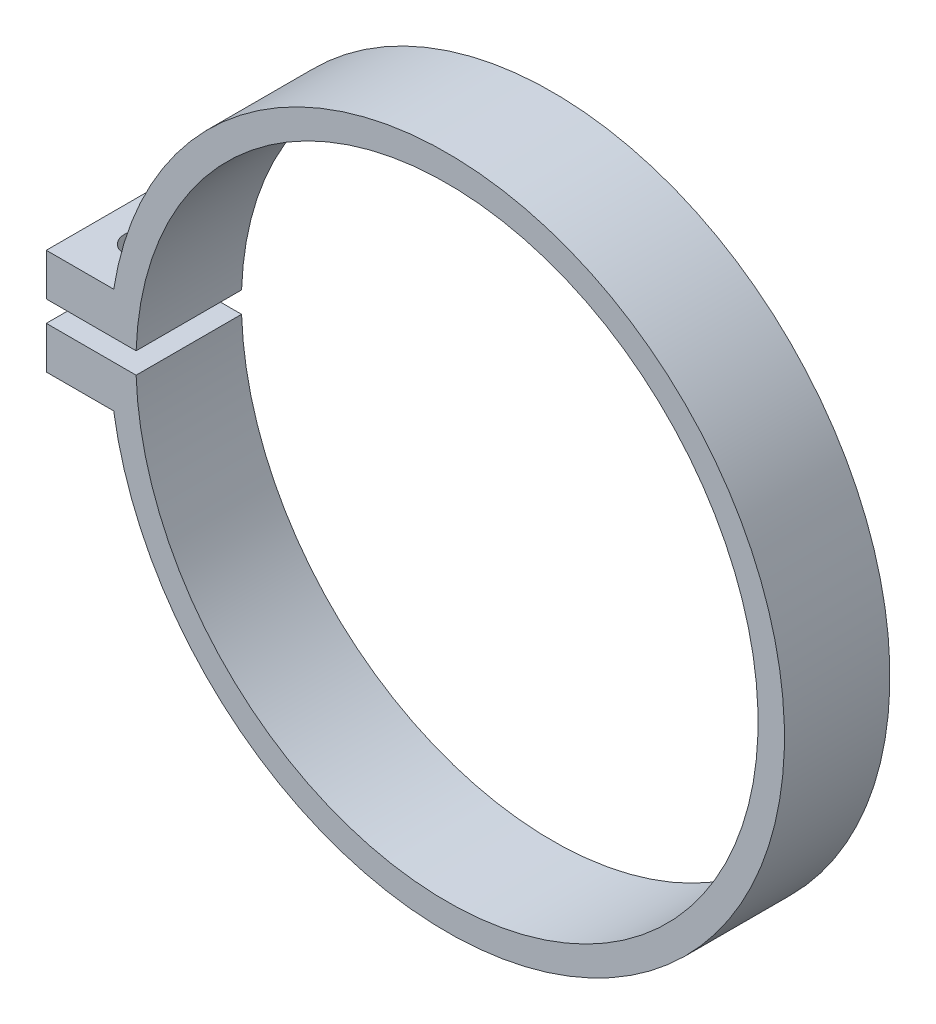
from build123d import *

# Parameters (mm, degrees)
SKETCH1_R               = 32
BOSS_EXTRUDE1_DEPTH     = 5
SKETCH4_W               = 38
SKETCH4_H               = 10
BOSS_EXTRUDE2_DEPTH     = 5
SKETCH5_R               = 29.5
SKETCH5_W               = 38
SKETCH5_H               = 2
CUT_EXTRUDE1_DEPTH      = 26.5
SKETCH6_R               = 1.6
CUT_EXTRUDE2_DEPTH      = 28
CUT_EXTRUDE2_DEPTH_BACK = 10


with BuildPart() as part:
    # Sketch1 → Boss-Extrude1 (new body, symmetric)
    with BuildSketch(Plane.XY):
        Circle(SKETCH1_R)
    extrude(amount=BOSS_EXTRUDE1_DEPTH, both=True)

    # Sketch4 → Boss-Extrude2 (add, symmetric)
    with BuildSketch(Plane.XY):
        with Locations((-19, 0)):
            Rectangle(SKETCH4_W, SKETCH4_H)
    extrude(amount=BOSS_EXTRUDE2_DEPTH, both=True)

    # Sketch5 → Cut-Extrude1 (cut)
    with BuildSketch(Plane.XY.offset(5)):
        Circle(SKETCH5_R)
        with Locations((-19, 0)):
            Rectangle(SKETCH5_W, SKETCH5_H)
    extrude(amount=-CUT_EXTRUDE1_DEPTH, mode=Mode.SUBTRACT)

    # Sketch6 → Cut-Extrude2 (cut, two sides)
    with BuildSketch(Plane(origin=(0, 5, 0), x_dir=(1, 0, 0), z_dir=(0, 1, 0))) as cut_extrude2_sk:
        with Locations((-34, 0)):
            Circle(SKETCH6_R)
    extrude(amount=CUT_EXTRUDE2_DEPTH, mode=Mode.SUBTRACT)
    extrude(cut_extrude2_sk.sketch, amount=-CUT_EXTRUDE2_DEPTH_BACK, mode=Mode.SUBTRACT)


solid = part.part
